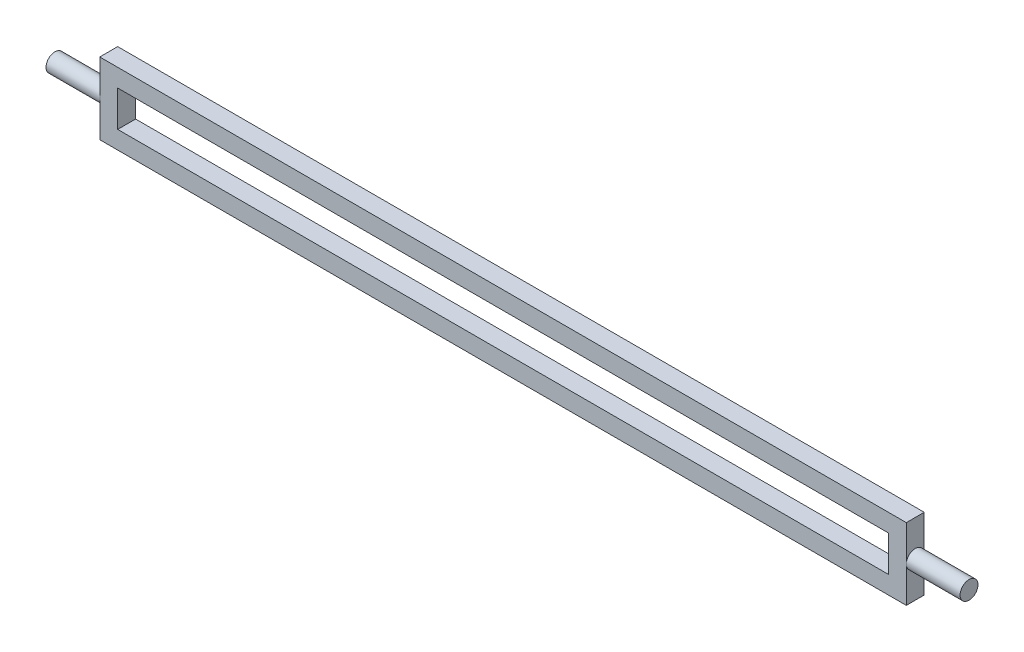
from build123d import *

# Parameters (mm, degrees)
SKETCH1_W           = 225
SKETCH1_H           = 20
BOSS_EXTRUDE1_DEPTH = 5
SKETCH2_R           = 2.5
BOSS_EXTRUDE2_DEPTH = 15
SKETCH3_R           = 2.5
BOSS_EXTRUDE3_DEPTH = 15
SKETCH4_W           = 215
SKETCH4_H           = 10
CUT_EXTRUDE1_DEPTH  = 6


with BuildPart() as part:
    # Sketch1 → Boss-Extrude1 (new body)
    with BuildSketch(Plane.XY):
        with Locations((112.5, 10)):
            Rectangle(SKETCH1_W, SKETCH1_H)
    extrude(amount=BOSS_EXTRUDE1_DEPTH)

    # Sketch2 → Boss-Extrude2 (add)
    with BuildSketch(Plane(origin=(225, 0, 0), x_dir=(0, 0, -1), z_dir=(1, 0, 0))):
        with Locations((-2.5, 10)):
            Circle(SKETCH2_R)
    extrude(amount=BOSS_EXTRUDE2_DEPTH)

    # Sketch3 → Boss-Extrude3 (add)
    with BuildSketch(Plane.ZY):
        with Locations((2.5, 10)):
            Circle(SKETCH3_R)
    extrude(amount=BOSS_EXTRUDE3_DEPTH)

    # Sketch4 → Cut-Extrude1 (cut, through all)
    with BuildSketch(Plane.XY.offset(5)):
        with Locations((112.5, 10)):
            Rectangle(SKETCH4_W, SKETCH4_H)
    extrude(amount=-CUT_EXTRUDE1_DEPTH, mode=Mode.SUBTRACT)


solid = part.part
